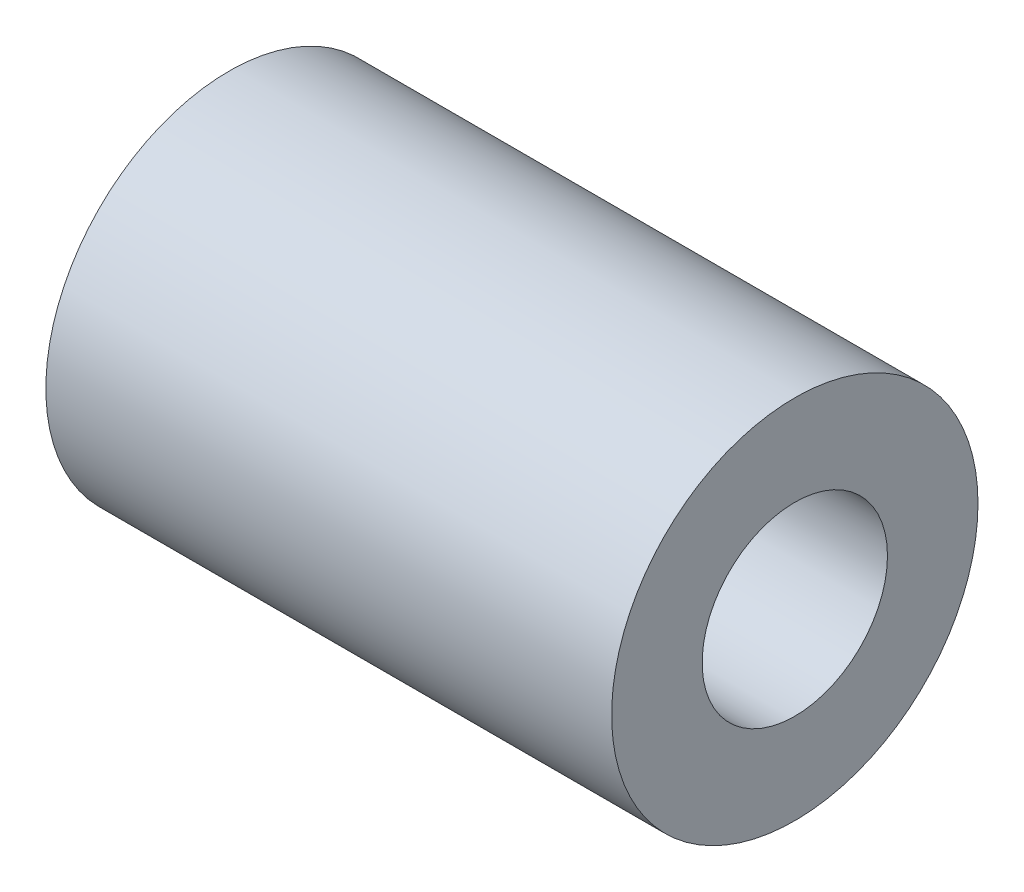
from build123d import *

# Parameters (mm, degrees)
SKETCH1_R           = 5.14
SKETCH1_R_2         = 2.6
BOSS_EXTRUDE1_DEPTH = 15.875


with BuildPart() as part:
    # Sketch1 → Boss-Extrude1 (new body)
    with BuildSketch(Plane(origin=(0, 0, 0), x_dir=(0, 0, -1), z_dir=(1, 0, 0))):
        Circle(SKETCH1_R)
        Circle(SKETCH1_R_2, mode=Mode.SUBTRACT)
    extrude(amount=BOSS_EXTRUDE1_DEPTH)


solid = part.part
